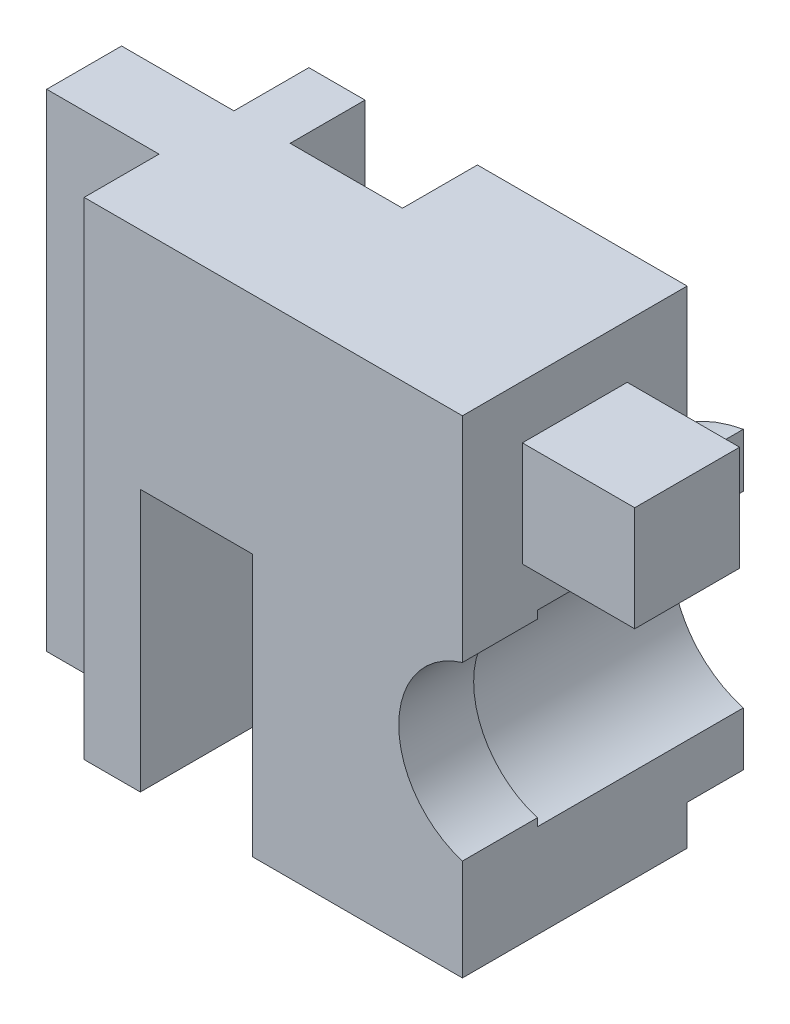
from build123d import *

# Parameters (mm, degrees)
SKETCH1_R            = 1
BOSS_EXTRUDE1_DEPTH  = 6
SKETCH2_R            = 2.6
CUT_EXTRUDE1_DEPTH   = 6
SKETCH3_W            = 7.6
SKETCH3_H            = 13
BOSS_EXTRUDE2_DEPTH  = 6
BOSS_EXTRUDE5_START  = -5
SKETCH6_W            = 3
SKETCH6_H            = 2
BOSS_EXTRUDE5_DEPTH  = 13
BOSS_EXTRUDE6_START  = -7.5
SKETCH10_R           = 4
SKETCH10_R_2         = 2.6
BOSS_EXTRUDE6_DEPTH  = 1.5
BOSS_EXTRUDE7_START  = -6
SKETCH12_R           = 2.6
SKETCH12_R_2         = 2.4
BOSS_EXTRUDE7_DEPTH  = 2
CUT_EXTRUDE2_DEPTH   = 7
SKETCH14_W           = 3
SKETCH14_H           = 6
CUT_EXTRUDE3_DEPTH   = 2
SKETCH15_W           = 0.2
SKETCH15_H           = 13
CUT_EXTRUDE5_DEPTH   = 7.5
SKETCH16_W           = 3
SKETCH16_H           = 3
CUT_EXTRUDE6_DEPTH   = 3
SKETCH17_W           = 2.8
SKETCH17_H           = 2.8
BOSS_EXTRUDE9_DEPTH  = 3
BOSS_EXTRUDE10_START = 24.4
SKETCH17_2_W         = 2.8
SKETCH17_2_H         = 2.8
BOSS_EXTRUDE10_DEPTH = 3
SKETCH18_W           = 29.7
SKETCH18_H           = 13
CUT_EXTRUDE11_DEPTH  = 9
SKETCH21_W           = 2.8
SKETCH21_H           = 2.8
BOSS_EXTRUDE12_DEPTH = 3


with BuildPart() as part:
    # Sketch1 → Boss-Extrude1 (new body)
    with BuildSketch(Plane.XY):
        with BuildLine():
            ThreePointArc((3.75, -5), (4.47902769, -4.358991965), (5.1, -3.61282438))
            Line((5.1, -3.61282438), (5.1, 3.61282438))
            ThreePointArc((5.1, 3.61282438), (0, 6.25), (-5.1, 3.61282438))
            Line((-5.1, 3.61282438), (-5.1, -3.61282438))
            ThreePointArc((-5.1, -3.61282438), (-4.47902769, -4.358991965), (-3.75, -5))
            Line((-3.75, -5), (-14.7, -5))
            Line((-14.7, -5), (-14.7, 8))
            Line((-14.7, 8), (14.7, 8))
            Line((14.7, 8), (14.7, -5))
            Line((14.7, -5), (3.75, -5))
        make_face()
        with Locations((11.5, 0)):
            Circle(SKETCH1_R, mode=Mode.SUBTRACT)
        with Locations((-11.5, 0)):
            Circle(SKETCH1_R, mode=Mode.SUBTRACT)
    extrude(amount=BOSS_EXTRUDE1_DEPTH)

    # Sketch2 → Cut-Extrude1 (cut)
    with BuildSketch(Plane.XY):
        with Locations((-11.5, 0)):
            Circle(SKETCH2_R)
        with Locations((11.5, 0)):
            Circle(SKETCH2_R)
    extrude(amount=CUT_EXTRUDE1_DEPTH, mode=Mode.SUBTRACT)

    # Sketch3 → Boss-Extrude2 (add)
    with BuildSketch(Plane.XY):
        with Locations((-18.5, 1.5)):
            Rectangle(SKETCH3_W, SKETCH3_H)
    extrude(amount=BOSS_EXTRUDE2_DEPTH)

    # Sketch6 → Boss-Extrude5 (add)
    with BuildSketch(Plane(origin=(0, 0, 0), x_dir=(1, 0, 0), z_dir=(0, 1, 0)).offset(BOSS_EXTRUDE5_START)):
        with Locations((-23.8, -3)):
            Rectangle(SKETCH6_W, SKETCH6_H)
        with Locations((16.2, -3)):
            Rectangle(SKETCH6_W, SKETCH6_H)
    extrude(amount=BOSS_EXTRUDE5_DEPTH)

    # Sketch10 → Boss-Extrude6 (add)
    with BuildSketch(Plane.XY.offset(6).offset(BOSS_EXTRUDE6_START)):
        with Locations((-11.5, 0)):
            Circle(SKETCH10_R)
        with Locations((-11.5, 0)):
            Circle(SKETCH10_R_2, mode=Mode.SUBTRACT)
        with BuildLine():
            Line((14.7, 2.4), (14.7, -2.4))
            ThreePointArc((14.7, -2.4), (7.5, 0), (14.7, 2.4))
        make_face()
        with Locations((11.5, 0)):
            Circle(SKETCH10_R_2, mode=Mode.SUBTRACT)
    extrude(amount=BOSS_EXTRUDE6_DEPTH)

    # Sketch12 → Boss-Extrude7 (add)
    with BuildSketch(Plane(origin=(0, 0, 0), x_dir=(-1, 0, 0), z_dir=(0, 0, -1)).offset(BOSS_EXTRUDE7_START)):
        with Locations((11.5, 0)):
            Circle(SKETCH12_R)
        with Locations((11.5, 0)):
            Circle(SKETCH12_R_2, mode=Mode.SUBTRACT)
        with Locations((-11.5, 0)):
            Circle(SKETCH12_R)
        with Locations((-11.5, 0)):
            Circle(SKETCH12_R_2, mode=Mode.SUBTRACT)
    extrude(amount=BOSS_EXTRUDE7_DEPTH)

    # Sketch13 → Cut-Extrude2 (cut)
    with BuildSketch(Plane.XZ.offset(5)):
        Polygon((-22.3, 0), (-16.3, 0), (-16.3, 2), (-17.8, 2), (-17.8, 6), (-20.8, 6), (-20.8, 2), (-22.3, 2), align=None)
    extrude(amount=-CUT_EXTRUDE2_DEPTH, mode=Mode.SUBTRACT)

    # Sketch14 → Cut-Extrude3 (cut)
    with BuildSketch(Plane(origin=(0, 0, 0), x_dir=(-1, 0, 0), z_dir=(0, 0, -1))):
        with Locations((19.3, 5)):
            Rectangle(SKETCH14_W, SKETCH14_H)
    extrude(amount=-CUT_EXTRUDE3_DEPTH, mode=Mode.SUBTRACT)

    # Sketch15 → Cut-Extrude5 (cut, symmetric)
    with BuildSketch(Plane.XY):
        with Locations((-12.1, 1.5)):
            Rectangle(SKETCH15_W, SKETCH15_H)
        with Locations((12.1, 1.5)):
            Rectangle(SKETCH15_W, SKETCH15_H)
    extrude(amount=CUT_EXTRUDE5_DEPTH, both=True, mode=Mode.SUBTRACT)

    # Sketch16 → Cut-Extrude6 (cut)
    with BuildSketch(Plane(origin=(12, 0, 0), x_dir=(0, 0, -1), z_dir=(1, 0, 0))):
        with Locations((-3, 5.173669459)):
            Rectangle(SKETCH16_W, SKETCH16_H)
    cut_extrude6 = extrude(amount=-CUT_EXTRUDE6_DEPTH, mode=Mode.SUBTRACT)

    # Mirror1: Cut-Extrude6 across plane
    add(cut_extrude6.mirror(Plane(origin=(0, 0, 0), x_dir=(0, 0, 1), z_dir=(1, 0, 0))), mode=Mode.SUBTRACT)

    # Sketch17 → Boss-Extrude9 (add)
    with BuildSketch(Plane(origin=(-12.2, 0, 0), x_dir=(0, 0, -1), z_dir=(1, 0, 0))):
        with Locations((-3, 5.173669459)):
            Rectangle(SKETCH17_W, SKETCH17_H)
    extrude(amount=BOSS_EXTRUDE9_DEPTH)

    # Sketch17_2 → Boss-Extrude10 (add)
    with BuildSketch(Plane(origin=(-12.2, 0, 0), x_dir=(0, 0, -1), z_dir=(1, 0, 0)).offset(BOSS_EXTRUDE10_START)):
        with Locations((-3, 5.173669459)):
            Rectangle(SKETCH17_2_W, SKETCH17_2_H)
    extrude(amount=-BOSS_EXTRUDE10_DEPTH)

    # Sketch18 → Cut-Extrude11 (cut, symmetric)
    with BuildSketch(Plane.XY):
        with Locations((2.85, 1.5)):
            Rectangle(SKETCH18_W, SKETCH18_H)
    extrude(amount=CUT_EXTRUDE11_DEPTH, both=True, mode=Mode.SUBTRACT)

    # Sketch21 → Boss-Extrude12 (add)
    with BuildSketch(Plane(origin=(-12.2, 0, 0), x_dir=(0, 0, -1), z_dir=(1, 0, 0))):
        with Locations((-3, 5.173669459)):
            Rectangle(SKETCH21_W, SKETCH21_H)
    extrude(amount=BOSS_EXTRUDE12_DEPTH)


solid = part.part
